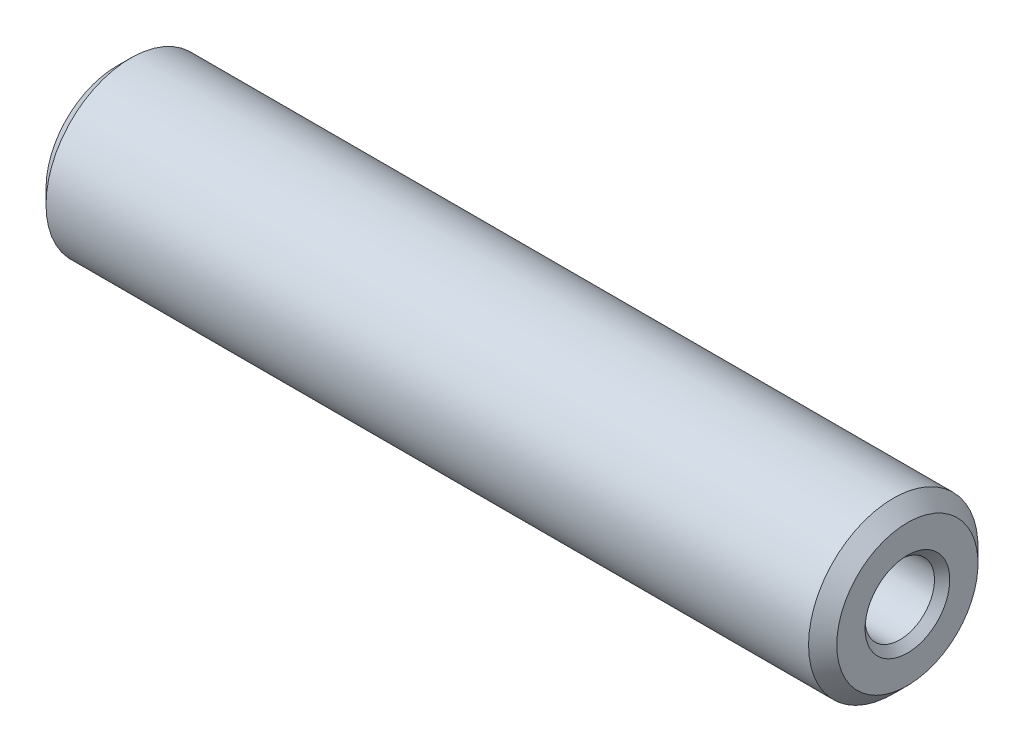
from build123d import *


with BuildPart() as part:
    # Sketch1 → Revolve1 (revolve)
    with BuildSketch(Plane(origin=(0, 0, 0), x_dir=(-1, 0, 0), z_dir=(0, 0, -1))):
        Polygon((-17.209852156, 1.2295), (-16.500000004, 7e-09), (-11.5, 7e-09), (-10.790147844, 1.2295), (-0.2705, 1.2295), (0, 1.5), (0, 2.5), (-0.5, 3), (-27.5, 3), (-28, 2.5), (-28, 1.5), (-27.7295, 1.2295), align=None)
    revolve(axis=Axis((28, 7e-09, 0), (-1, 0, 0)))


solid = part.part
